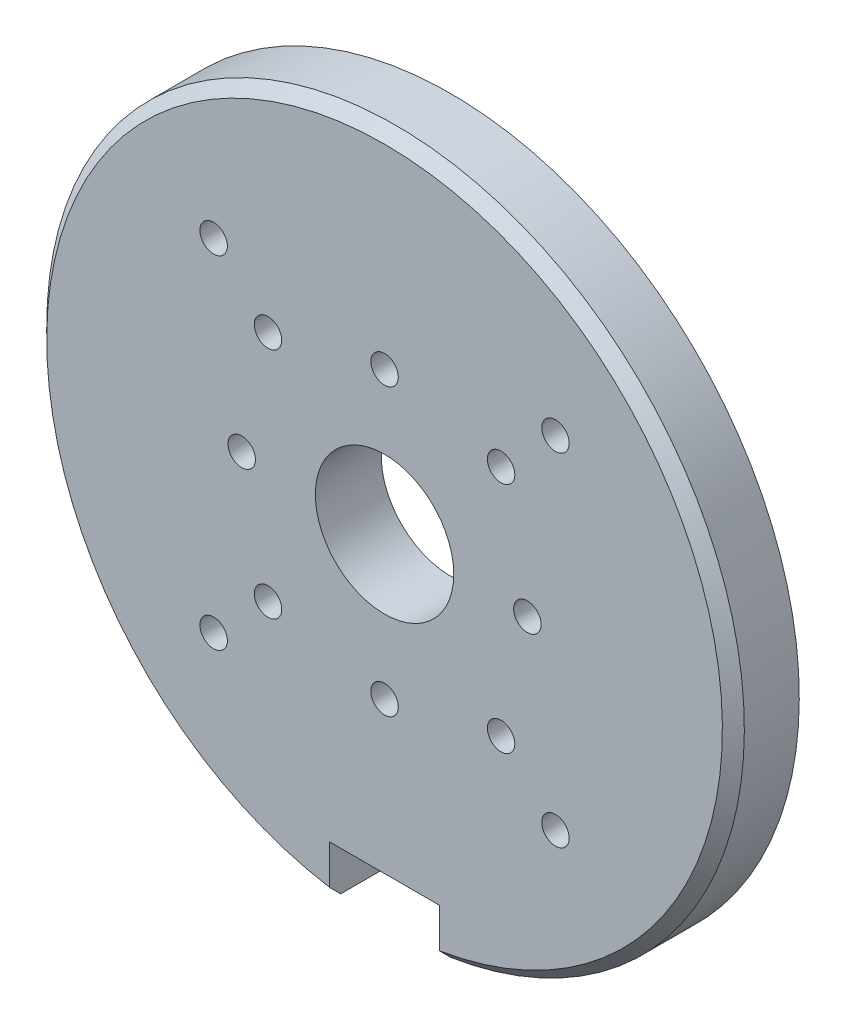
from build123d import *

# Parameters (mm, degrees)
SKETCH_1_R          = 31.75
EXTRUDE_1_DEPTH     = 6
SKETCH_2_W          = 10
SKETCH_2_H          = 10
CUT_EXTRUDE_1_DEPTH = 7
M3X0_52_D           = 2.5
M3X0_51_D           = 2.5
SKETCH_8_R          = 6.3
CUT_EXTRUDE_2_DEPTH = 7
CHAMFER_1_SIZE      = 1


with BuildPart() as part:
    # Эскиз1 → Бобышка-Вытянуть1 (new body)
    with BuildSketch(Plane.XY):
        Circle(SKETCH_1_R)
    extrude(amount=EXTRUDE_1_DEPTH)

    # Эскиз2 → Вырез-Вытянуть1 (cut, through all)
    with BuildSketch(Plane.XY.offset(6)):
        with Locations((0, -31.75)):
            Rectangle(SKETCH_2_W, SKETCH_2_H)
    extrude(amount=-CUT_EXTRUDE_1_DEPTH, mode=Mode.SUBTRACT)

    # Отверстие обработанное метчиком M3x0.52 (through all)
    with Locations(Plane.XY.offset(6)):
        with Locations((0, 13), (13, 0), (-13, 0), (0, -13)):
            Hole(M3X0_52_D / 2)

    # Отверстие обработанное метчиком M3x0.51 (through all)
    with Locations(Plane.XY.offset(6)):
        with Locations((-15.556349186, 15.556349186), (-15.556349186, -15.556349186), (15.556349186, -15.556349186), (15.556349186, 15.556349186), (10.606601718, 10.606601718), (-10.606601718, 10.606601718), (-10.606601718, -10.606601718), (10.606601718, -10.606601718)):
            Hole(M3X0_51_D / 2)

    # Эскиз8 → Вырез-Вытянуть2 (cut, through all)
    with BuildSketch(Plane.XY.offset(6)):
        Circle(SKETCH_8_R)
    extrude(amount=-CUT_EXTRUDE_2_DEPTH, mode=Mode.SUBTRACT)

    # Фаска1
    chamfer_1_edges = [part.edges().sort_by_distance(p)[0] for p in [
        (0, 31.75, 6),
    ]]
    chamfer(chamfer_1_edges, length=CHAMFER_1_SIZE)


solid = part.part
